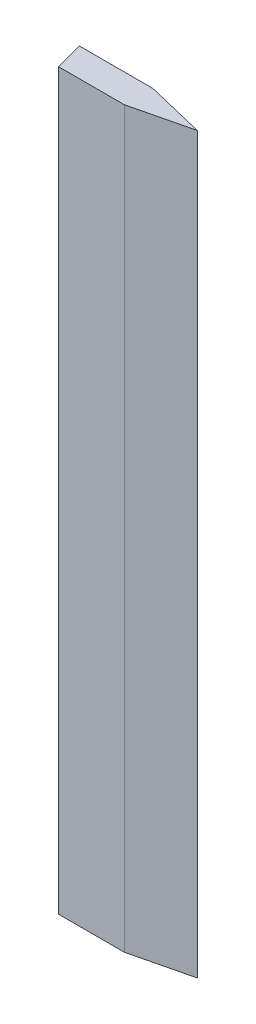
from build123d import *

# Parameters (mm, degrees)
BOSS_EXTRUDE1_DEPTH = 63.5


with BuildPart() as part:
    # Sketch1 → Boss-Extrude1 (new body)
    with BuildSketch(Plane(origin=(0, 0, 0), x_dir=(1, 0, 0), z_dir=(0, 1, 0))):
        Polygon((0, 0), (6.35, 0), (11.43, -1.22682), (6.35, -2.45364), (0.657450857, -2.45364), align=None)
    extrude(amount=BOSS_EXTRUDE1_DEPTH)


solid = part.part
